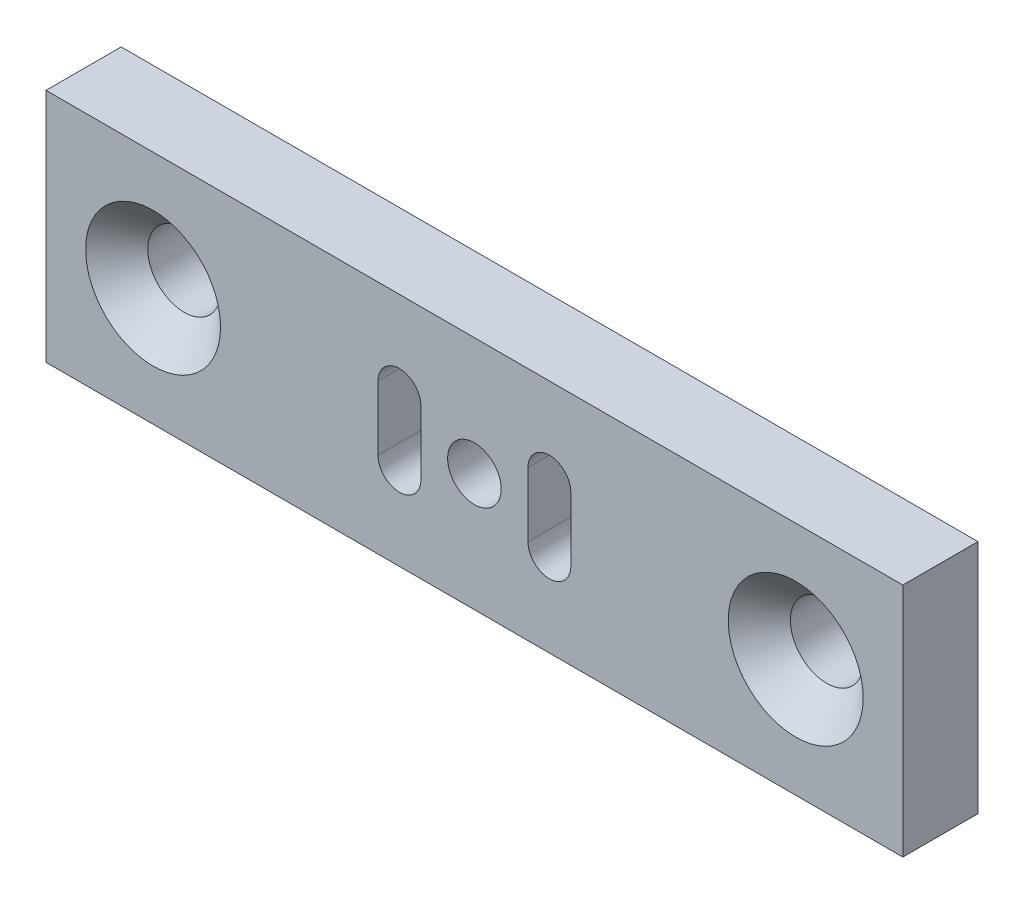
from build123d import *

# Parameters (mm, degrees)
ESQUISSE1_W                                        = 40
ESQUISSE1_H                                        = 11
ESQUISSE1_R                                        = 4
BOSS_EXTRU_1_DEPTH                                 = 9.51
ESQUISSE16_W                                       = 40
ESQUISSE16_H                                       = 11
BOSS_EXTRU_2_DEPTH                                 = 7
D_GAGEMENT_M32_D                                   = 2.5
ENL_V_MAT_EXTRU_1_DEPTH                            = 7
CHAMBRAGE_POUR_VIS_T_TE_RONDE_BOMB_E_M_D           = 3.4
CHAMBRAGE_POUR_VIS_T_TE_RONDE_BOMB_E_M_CBORE_D     = 6
CHAMBRAGE_POUR_VIS_T_TE_RONDE_BOMB_E_M_CBORE_DEPTH = 2.4
FRAISAGE_POUR_VIS_T_TE_FRAIS_E_M31_D               = 3.4
FRAISAGE_POUR_VIS_T_TE_FRAIS_E_M31_DEPTH           = 6
FRAISAGE_POUR_VIS_T_TE_FRAIS_E_M31_CSINK_D         = 6.3
FRAISAGE_POUR_VIS_T_TE_FRAIS_E_M31_CSINK_ANGLE     = 90
FRAISAGE_POUR_VIS_T_TE_FRAIS_E_M31_TIP             = 1.021463052
ESQUISSE33_W                                       = 53.617438424
ESQUISSE33_H                                       = 31.43157248
ENL_V_MAT_EXTRU_4_DEPTH                            = 13


with BuildPart() as part:
    # Esquisse1 → Boss.-Extru.1 (new body)
    with BuildSketch(Plane.XY):
        Rectangle(ESQUISSE1_W, ESQUISSE1_H)
        Circle(ESQUISSE1_R, mode=Mode.SUBTRACT)
    extrude(amount=BOSS_EXTRU_1_DEPTH)

    # Esquisse16 → Boss.-Extru.2 (add)
    with BuildSketch(Plane.XY.offset(9.51)):
        Rectangle(ESQUISSE16_W, ESQUISSE16_H)
    extrude(amount=BOSS_EXTRU_2_DEPTH)

    # Dégagement M32 (through all)
    with Locations(Plane.XY.offset(16.51)):
        with Locations((0, 0)):
            Hole(D_GAGEMENT_M32_D / 2)

    # Esquisse19 → Enlèv. mat.-Extru.1 (cut)
    with BuildSketch(Plane.XY.offset(16.51)):
        with BuildLine():
            Line((-2.5, 1.5), (-2.5, -1.5))
            ThreePointArc((-2.5, -1.5), (-3.5, -2.5), (-4.5, -1.5))
            Line((-4.5, -1.5), (-4.5, 1.5))
            ThreePointArc((-4.5, 1.5), (-3.5, 2.5), (-2.5, 1.5))
        make_face()
        with BuildLine():
            Line((4.5, 1.5), (4.5, -1.5))
            ThreePointArc((4.5, -1.5), (3.5, -2.5), (2.5, -1.5))
            Line((2.5, -1.5), (2.5, 1.5))
            ThreePointArc((2.5, 1.5), (3.5, 2.5), (4.5, 1.5))
        make_face()
    extrude(amount=-ENL_V_MAT_EXTRU_1_DEPTH, mode=Mode.SUBTRACT)

    # Chambrage pour vis _ t_te ronde bomb_e M (through all)
    with Locations(Plane(origin=(0, 5.5, 0), x_dir=(1, 0, 0), z_dir=(0, 1, 0))):
        with Locations((14, -6.51), (-14, -6.51)):
            CounterBoreHole(CHAMBRAGE_POUR_VIS_T_TE_RONDE_BOMB_E_M_D / 2, CHAMBRAGE_POUR_VIS_T_TE_RONDE_BOMB_E_M_CBORE_D / 2, CHAMBRAGE_POUR_VIS_T_TE_RONDE_BOMB_E_M_CBORE_DEPTH)

    # Fraisage pour vis à tête fraisée M31
    with Locations(Plane.XY.offset(16.51)):
        with Locations((-15, 0), (15, 0)):
            CounterSinkHole(FRAISAGE_POUR_VIS_T_TE_FRAIS_E_M31_D / 2, FRAISAGE_POUR_VIS_T_TE_FRAIS_E_M31_CSINK_D / 2, depth=FRAISAGE_POUR_VIS_T_TE_FRAIS_E_M31_DEPTH, counter_sink_angle=FRAISAGE_POUR_VIS_T_TE_FRAIS_E_M31_CSINK_ANGLE)
            with Locations((0, 0, -(FRAISAGE_POUR_VIS_T_TE_FRAIS_E_M31_DEPTH + FRAISAGE_POUR_VIS_T_TE_FRAIS_E_M31_TIP / 2))):  # 118° drill point
                Cone(0, FRAISAGE_POUR_VIS_T_TE_FRAIS_E_M31_D / 2, FRAISAGE_POUR_VIS_T_TE_FRAIS_E_M31_TIP, mode=Mode.SUBTRACT)

    # Esquisse33 → Enlèv. mat.-Extru.4 (cut)
    with BuildSketch(Plane(origin=(0, 0, 0), x_dir=(-1, 0, 0), z_dir=(0, 0, -1))):
        Rectangle(ESQUISSE33_W, ESQUISSE33_H)
    extrude(amount=-ENL_V_MAT_EXTRU_4_DEPTH, mode=Mode.SUBTRACT)


solid = part.part
